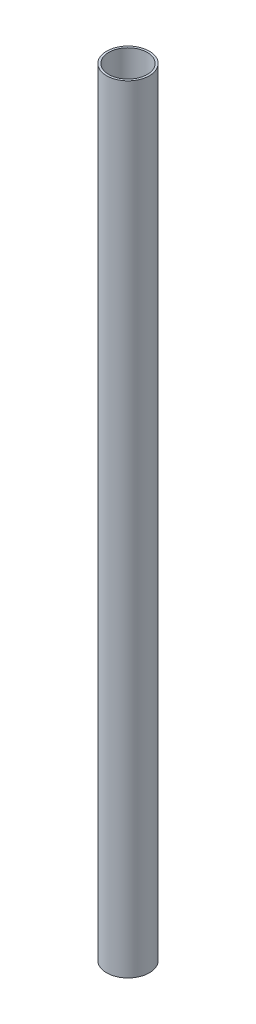
from build123d import *

# Parameters (mm, degrees)
SKETCH1_R           = 15.875
SKETCH1_R_2         = 14.2875
BOSS_EXTRUDE1_DEPTH = 577.85


with BuildPart() as part:
    # Sketch1 → Boss-Extrude1 (new body)
    with BuildSketch(Plane(origin=(0, 0, 0), x_dir=(1, 0, 0), z_dir=(0, 1, 0))):
        Circle(SKETCH1_R)
        Circle(SKETCH1_R_2, mode=Mode.SUBTRACT)
    extrude(amount=BOSS_EXTRUDE1_DEPTH)


solid = part.part
